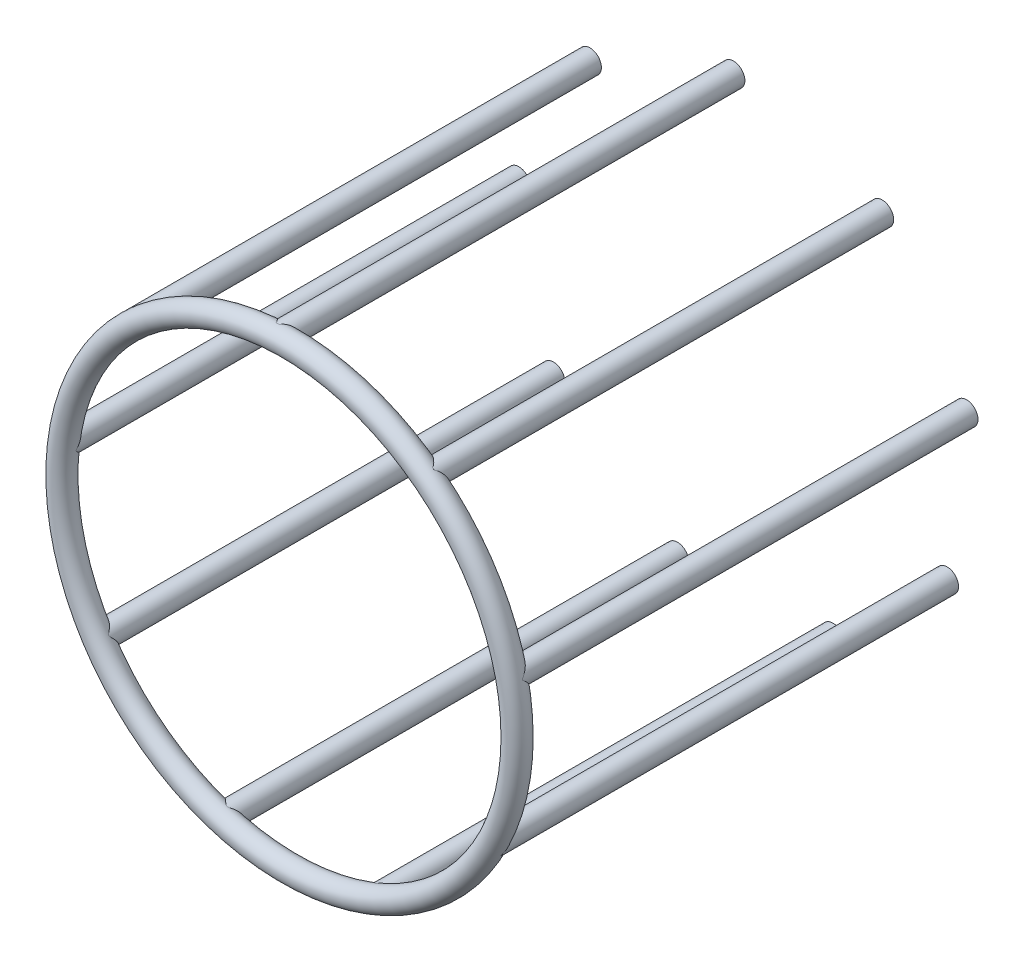
from build123d import *

# Parameters (mm, degrees)
SKIZZE1_R                         = 2.5
AUFSATZ_LINEAR_AUSTRAGEN1_DEPTH   = 100
AUFSATZ_LINEAR_AUSTRAGEN1_2_DEPTH = 100
AUFSATZ_LINEAR_AUSTRAGEN1_3_DEPTH = 100
AUFSATZ_LINEAR_AUSTRAGEN1_4_DEPTH = 100
AUFSATZ_LINEAR_AUSTRAGEN1_5_DEPTH = 100
AUFSATZ_LINEAR_AUSTRAGEN1_6_DEPTH = 100
AUFSATZ_LINEAR_AUSTRAGEN1_7_DEPTH = 100
AUFSATZ_LINEAR_AUSTRAGEN1_8_DEPTH = 100
AUFSATZ_LINEAR_AUSTRAGEN1_9_DEPTH = 100
AUSTRAGUNG1_PROFILE_R             = 2.5


with BuildPart() as part:
    # Skizze1 → Aufsatz-Linear austragen1 (new body)
    with BuildSketch(Plane.XY):
        with Locations((-42.019348311, -27.099342566)):
            Circle(SKIZZE1_R)
    extrude(amount=AUFSATZ_LINEAR_AUSTRAGEN1_DEPTH)


with BuildPart() as body_2:
    # Skizze1 → Aufsatz-Linear austragen1 2 (new body)
    with BuildSketch(Plane.XY):
        with Locations((-14.769566645, -47.768817246)):
            Circle(SKIZZE1_R)
    extrude(amount=AUFSATZ_LINEAR_AUSTRAGEN1_2_DEPTH)


with BuildPart() as body_3:
    # Skizze1 → Aufsatz-Linear austragen1 3 (new body)
    with BuildSketch(Plane.XY):
        with Locations((19.391059399, -46.086731446)):
            Circle(SKIZZE1_R)
    extrude(amount=AUFSATZ_LINEAR_AUSTRAGEN1_3_DEPTH)


with BuildPart() as body_4:
    # Skizze1 → Aufsatz-Linear austragen1 4 (new body)
    with BuildSketch(Plane.XY):
        with Locations((44.478393243, -22.840151805)):
            Circle(SKIZZE1_R)
    extrude(amount=AUFSATZ_LINEAR_AUSTRAGEN1_4_DEPTH)


with BuildPart() as body_5:
    # Skizze1 → Aufsatz-Linear austragen1 5 (new body)
    with BuildSketch(Plane.XY):
        with Locations((48.753792567, 11.093588705)):
            Circle(SKIZZE1_R)
    extrude(amount=AUFSATZ_LINEAR_AUSTRAGEN1_5_DEPTH)


with BuildPart() as body_6:
    # Skizze1 → Aufsatz-Linear austragen1 6 (new body)
    with BuildSketch(Plane.XY):
        with Locations((30.21675051, 39.836515769)):
            Circle(SKIZZE1_R)
    extrude(amount=AUFSATZ_LINEAR_AUSTRAGEN1_6_DEPTH)


with BuildPart() as body_7:
    # Skizze1 → Aufsatz-Linear austragen1 7 (new body)
    with BuildSketch(Plane.XY):
        with Locations((-2.459044932, 49.939494371)):
            Circle(SKIZZE1_R)
    extrude(amount=AUFSATZ_LINEAR_AUSTRAGEN1_7_DEPTH)


with BuildPart() as body_8:
    # Skizze1 → Aufsatz-Linear austragen1 8 (new body)
    with BuildSketch(Plane.XY):
        with Locations((-33.984225921, 36.675228541)):
            Circle(SKIZZE1_R)
    extrude(amount=AUFSATZ_LINEAR_AUSTRAGEN1_8_DEPTH)


with BuildPart() as body_9:
    # Skizze1 → Aufsatz-Linear austragen1 9 (new body)
    with BuildSketch(Plane.XY):
        with Locations((-49.607809909, 6.250215677)):
            Circle(SKIZZE1_R)
    extrude(amount=AUFSATZ_LINEAR_AUSTRAGEN1_9_DEPTH)


with BuildPart() as body_10:
    # Austragung1: sweep along a path in Skizze2
    with BuildLine(Plane.XY.offset(100)) as austragung1_path:
        CenterArc((0, 0), 50, 0, 360)
    # Austragung1 profile (on start of the path) → Austragung1 (sweep)
    with BuildSketch(Plane(origin=(50, 0, 100), x_dir=(0, 0, 1), z_dir=(0, 1, 0))):
        Circle(AUSTRAGUNG1_PROFILE_R)
    sweep(path=austragung1_path.line)


solid = Compound([part.part, body_2.part, body_3.part, body_4.part, body_5.part, body_6.part, body_7.part, body_8.part, body_9.part, body_10.part])
